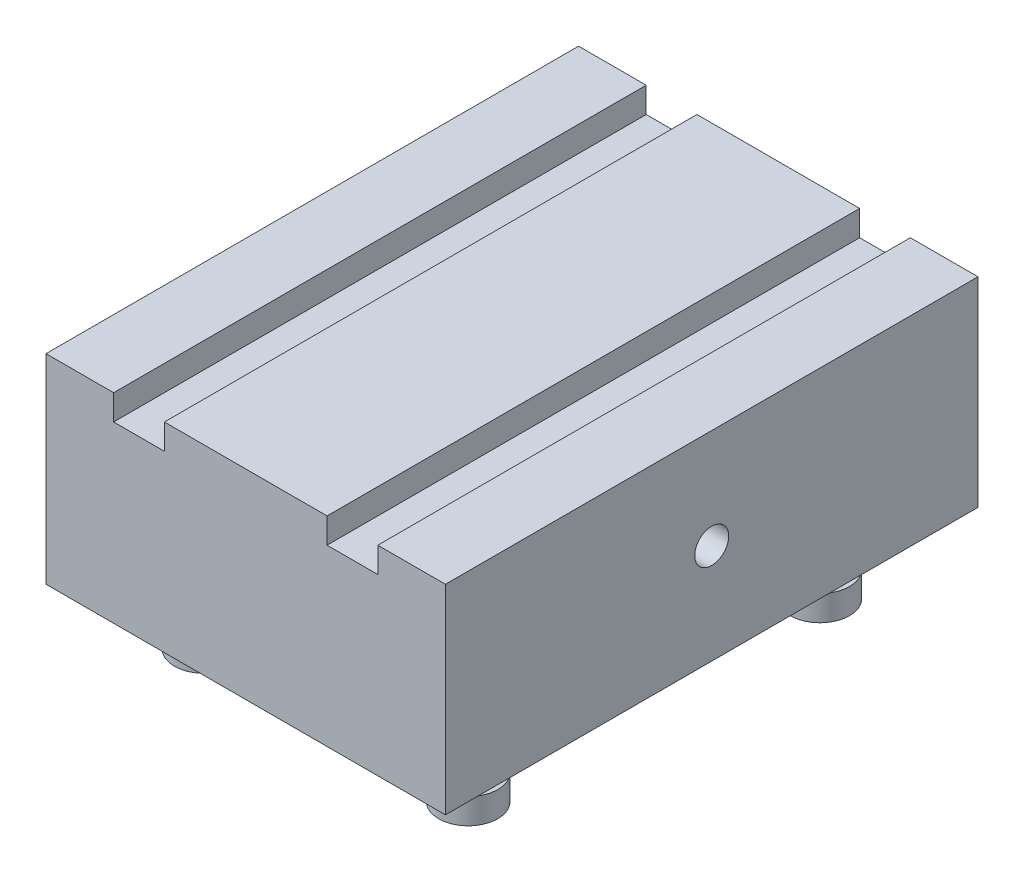
from build123d import *

# Parameters (mm, degrees)
SKETCH1_W               = 59.999999888
SKETCH1_H               = 80
BOSS_EXTRUDE1_DEPTH     = 30
CUT_EXTRUDE1_DEPTH      = 81
SKETCH3_R               = 4.445
BOSS_EXTRUDE2_DEPTH     = 3.81
SKETCH4_R               = 2.54
BOSS_EXTRUDE3_DEPTH     = 2.54
SKETCH5_R               = 4.445
BOSS_EXTRUDE4_DEPTH     = 3.81
F_1_4_20_TAPPED_HOLE1_D = 5.1054


with BuildPart() as part:
    # Sketch1 → Boss-Extrude1 (new body)
    with BuildSketch(Plane(origin=(0, 0, 0), x_dir=(1, 0, 0), z_dir=(0, 1, 0))):
        with Locations((29.999999944, 40)):
            Rectangle(SKETCH1_W, SKETCH1_H)
    extrude(amount=-BOSS_EXTRUDE1_DEPTH)

    # Sketch2 → Cut-Extrude1 (cut, through all)
    with BuildSketch(Plane.XY):
        with BuildLine():
            ThreePointArc((13.97, -3.81), (11.275923164, -2.694076836), (10.16, 0))
            Line((10.16, 0), (10.16, -3.81))
            Line((10.16, -3.81), (13.97, -3.81))
        make_face()
        with BuildLine():
            Line((17.78, 0), (10.16, 0))
            ThreePointArc((10.16, 0), (11.275923164, -2.694076836), (13.97, -3.81))
            ThreePointArc((13.97, -3.81), (16.664076836, -2.694076836), (17.78, 0))
        make_face()
        with BuildLine():
            ThreePointArc((17.78, 0), (16.664076836, -2.694076836), (13.97, -3.81))
            Line((13.97, -3.81), (17.78, -3.81))
            Line((17.78, -3.81), (17.78, 0))
        make_face()
        with BuildLine():
            Line((49.839999888, 0), (42.219999888, 0))
            ThreePointArc((42.219999888, 0), (43.335923052, -2.694076836), (46.029999888, -3.81))
            ThreePointArc((46.029999888, -3.81), (48.724076724, -2.694076836), (49.839999888, 0))
        make_face()
        with BuildLine():
            ThreePointArc((46.029999888, -3.81), (43.335923052, -2.694076836), (42.219999888, 0))
            Line((42.219999888, 0), (42.219999888, -3.81))
            Line((42.219999888, -3.81), (46.029999888, -3.81))
        make_face()
        with BuildLine():
            ThreePointArc((49.839999888, 0), (48.724076724, -2.694076836), (46.029999888, -3.81))
            Line((46.029999888, -3.81), (49.839999888, -3.81))
            Line((49.839999888, -3.81), (49.839999888, 0))
        make_face()
    extrude(amount=-CUT_EXTRUDE1_DEPTH, mode=Mode.SUBTRACT)

    # Sketch3 → Boss-Extrude2 (add)
    with BuildSketch(Plane.XZ.offset(30)):
        with Locations((49.839999888, -13.584)):
            Circle(SKETCH3_R)
        with Locations((10.16, -13.584)):
            Circle(SKETCH3_R)
        with Locations((49.839999888, -66.416)):
            Circle(SKETCH3_R)
        with Locations((10.16, -66.416)):
            Circle(SKETCH3_R)
    extrude(amount=BOSS_EXTRUDE2_DEPTH)

    # Sketch4 → Boss-Extrude3 (add)
    with BuildSketch(Plane.XZ.offset(33.81)):
        with Locations((49.839999888, -13.584)):
            Circle(SKETCH4_R)
        with Locations((10.16, -13.584)):
            Circle(SKETCH4_R)
        with Locations((10.16, -66.416)):
            Circle(SKETCH4_R)
        with Locations((49.839999888, -66.416)):
            Circle(SKETCH4_R)
    extrude(amount=BOSS_EXTRUDE3_DEPTH)

    # Sketch5 → Boss-Extrude4 (add)
    with BuildSketch(Plane.XZ.offset(36.35)):
        with Locations((10.16, -13.584)):
            Circle(SKETCH5_R)
        with Locations((10.16, -66.416)):
            Circle(SKETCH5_R)
        with Locations((49.839999888, -66.416)):
            Circle(SKETCH5_R)
        with Locations((49.839999888, -13.584)):
            Circle(SKETCH5_R)
    extrude(amount=BOSS_EXTRUDE4_DEPTH)

    # 1/4-20 Tapped Hole1 (through all)
    with Locations(Plane(origin=(59.999999888, 0, 0), x_dir=(0, 0, -1), z_dir=(1, 0, 0))):
        with Locations((40, -15)):
            Hole(F_1_4_20_TAPPED_HOLE1_D / 2)


solid = part.part
